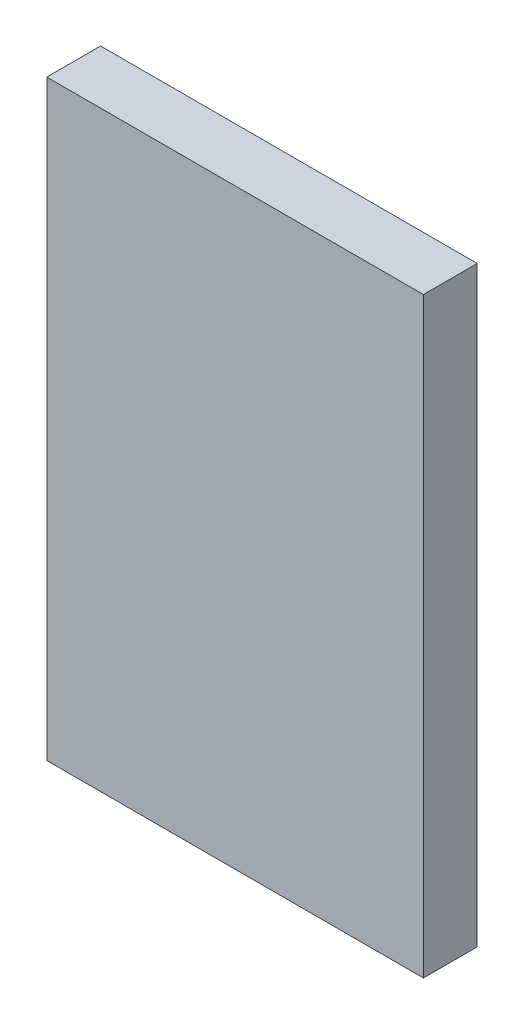
from build123d import *

# Parameters (mm, degrees)
SKETCH1_W           = 177.8
SKETCH1_H           = 279.4
BOSS_EXTRUDE1_DEPTH = 25.4


with BuildPart() as part:
    # Sketch1 → Boss-Extrude1 (new body)
    with BuildSketch(Plane.XY):
        Rectangle(SKETCH1_W, SKETCH1_H)
    extrude(amount=BOSS_EXTRUDE1_DEPTH)


solid = part.part
